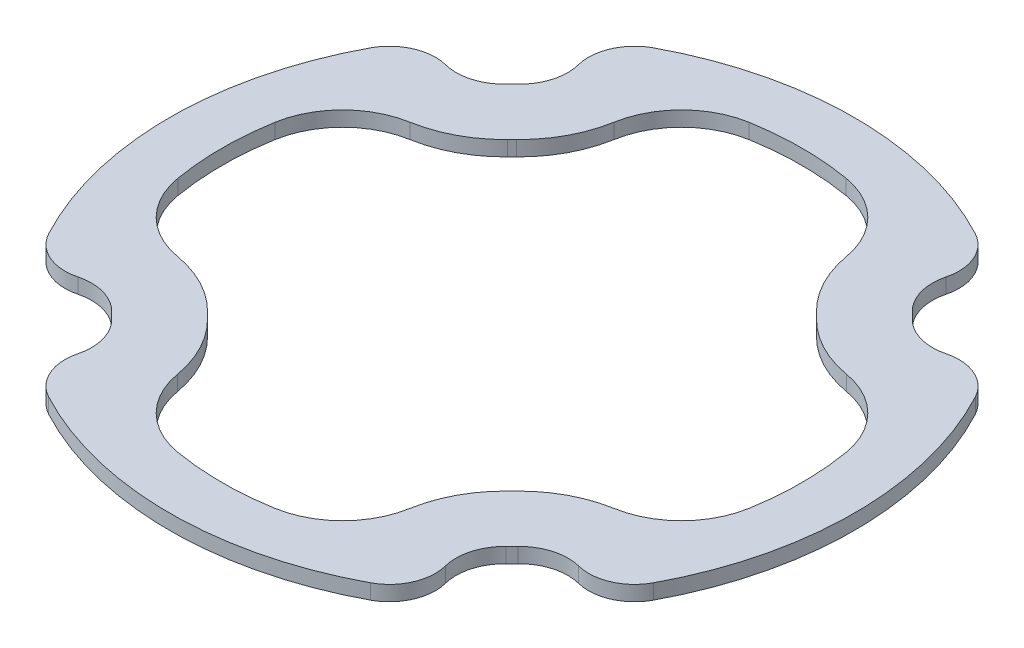
from build123d import *

# Parameters (mm, degrees)
PCB_OUTLINE_OUTER_DEPTH = 1
CUT_EXTRUDE2_DEPTH      = 1
CUT_EXTRUDE2_DEPTH_BACK = 2


with BuildPart() as part:
    # Internal Slab → PCB Outline Outer (new body)
    with BuildSketch(Plane(origin=(0, 0, 0), x_dir=(1, 0, 0), z_dir=(0, 1, 0))):
        with BuildLine():
            ThreePointArc((20.085113617, 10.68413361), (18.622288868, 12.043250737), (16.632261242, 12.207097181))
            ThreePointArc((16.632261242, 12.207097181), (14.943199752, 12.226998501), (13.492265758, 13.091935102))
            ThreePointArc((13.492265758, 13.091935102), (13.293607486, 13.293607486), (13.091935102, 13.492265758))
            ThreePointArc((13.091935102, 13.492265758), (12.226998501, 14.943199752), (12.207097181, 16.632261242))
            ThreePointArc((12.207097181, 16.632261242), (12.278791735, 17.008431368), (12.302815994, 17.390618375))
            ThreePointArc((12.302815994, 17.390618375), (11.867033623, 18.962276517), (10.68413361, 20.085113617))
            ThreePointArc((10.68413361, 20.085113617), (0, 22.75), (-10.68413361, 20.085113617))
            ThreePointArc((-10.68413361, 20.085113617), (-12.043250737, 18.622288868), (-12.207097181, 16.632261242))
            ThreePointArc((-12.207097181, 16.632261242), (-12.226998501, 14.943199752), (-13.091935102, 13.492265758))
            ThreePointArc((-13.091935102, 13.492265758), (-13.293607486, 13.293607486), (-13.492265758, 13.091935102))
            ThreePointArc((-13.492265758, 13.091935102), (-14.943199752, 12.226998501), (-16.632261242, 12.207097181))
            ThreePointArc((-16.632261242, 12.207097181), (-17.008431368, 12.278791735), (-17.390618375, 12.302815994))
            ThreePointArc((-17.390618375, 12.302815994), (-18.962276517, 11.867033623), (-20.085113617, 10.68413361))
            ThreePointArc((-20.085113617, 10.68413361), (-22.75, 0), (-20.085113617, -10.68413361))
            ThreePointArc((-20.085113617, -10.68413361), (-18.622288868, -12.043250737), (-16.632261242, -12.207097181))
            ThreePointArc((-16.632261242, -12.207097181), (-14.943199752, -12.226998501), (-13.492265758, -13.091935102))
            ThreePointArc((-13.492265758, -13.091935102), (-13.293607486, -13.293607486), (-13.091935102, -13.492265758))
            ThreePointArc((-13.091935102, -13.492265758), (-12.226998501, -14.943199752), (-12.207097181, -16.632261242))
            ThreePointArc((-12.207097181, -16.632261242), (-12.278791735, -17.008431368), (-12.302815994, -17.390618375))
            ThreePointArc((-12.302815994, -17.390618375), (-11.867033623, -18.962276517), (-10.68413361, -20.085113617))
            ThreePointArc((-10.68413361, -20.085113617), (0, -22.75), (10.68413361, -20.085113617))
            ThreePointArc((10.68413361, -20.085113617), (12.043250737, -18.622288868), (12.207097181, -16.632261242))
            ThreePointArc((12.207097181, -16.632261242), (12.226998501, -14.943199752), (13.091935102, -13.492265758))
            ThreePointArc((13.091935102, -13.492265758), (13.293607486, -13.293607486), (13.492265758, -13.091935102))
            ThreePointArc((13.492265758, -13.091935102), (14.943199752, -12.226998501), (16.632261242, -12.207097181))
            ThreePointArc((16.632261242, -12.207097181), (17.008431368, -12.278791735), (17.390618375, -12.302815994))
            ThreePointArc((17.390618375, -12.302815994), (18.962276517, -11.867033623), (20.085113617, -10.68413361))
            ThreePointArc((20.085113617, -10.68413361), (22.75, 0), (20.085113617, 10.68413361))
        make_face()
    extrude(amount=PCB_OUTLINE_OUTER_DEPTH)

    # Sketch7 → Cut-Extrude2 (cut, two sides)
    with BuildSketch(Plane(origin=(0, 1, 0), x_dir=(1, 0, 0), z_dir=(0, 1, 0))) as cut_extrude2_sk:
        with BuildLine():
            ThreePointArc((0, 19.25), (-1.616279551, 19.182026494), (-3.221144642, 18.978586017))
            ThreePointArc((-3.221144642, 18.978586017), (-6.18224043, 17.452869559), (-7.719604793, 14.497804451))
            ThreePointArc((-7.719604793, 14.497804451), (-8.503489746, 12.202965765), (-9.958227232, 10.262734061))
            ThreePointArc((-9.958227232, 10.262734061), (-10.111626971, 10.111626971), (-10.262734061, 9.958227232))
            ThreePointArc((-10.262734061, 9.958227232), (-12.202965765, 8.503489746), (-14.497804451, 7.719604793))
            ThreePointArc((-14.497804451, 7.719604793), (-17.452869559, 6.18224043), (-18.978586017, 3.221144642))
            ThreePointArc((-18.978586017, 3.221144642), (-19.182026494, 1.616279551), (-19.25, 0))
            ThreePointArc((-19.25, 0), (-19.182026494, -1.616279551), (-18.978586017, -3.221144642))
            ThreePointArc((-18.978586017, -3.221144642), (-17.452869559, -6.18224043), (-14.497804451, -7.719604793))
            ThreePointArc((-14.497804451, -7.719604793), (-12.202965765, -8.503489746), (-10.262734061, -9.958227232))
            ThreePointArc((-10.262734061, -9.958227232), (-10.111626971, -10.111626971), (-9.958227232, -10.262734061))
            ThreePointArc((-9.958227232, -10.262734061), (-8.503489746, -12.202965765), (-7.719604793, -14.497804451))
            ThreePointArc((-7.719604793, -14.497804451), (-6.18224043, -17.452869559), (-3.221144642, -18.978586017))
            ThreePointArc((-3.221144642, -18.978586017), (-1.616279551, -19.182026494), (0, -19.25))
            ThreePointArc((0, -19.25), (1.616279551, -19.182026494), (3.221144642, -18.978586017))
            ThreePointArc((3.221144642, -18.978586017), (6.18224043, -17.452869559), (7.719604793, -14.497804451))
            ThreePointArc((7.719604793, -14.497804451), (8.503489746, -12.202965765), (9.958227232, -10.262734061))
            ThreePointArc((9.958227232, -10.262734061), (10.111626971, -10.111626971), (10.262734061, -9.958227232))
            ThreePointArc((10.262734061, -9.958227232), (12.202965765, -8.503489746), (14.497804451, -7.719604793))
            ThreePointArc((14.497804451, -7.719604793), (17.452869559, -6.18224043), (18.978586017, -3.221144642))
            ThreePointArc((18.978586017, -3.221144642), (19.182026494, -1.616279551), (19.25, 0))
            ThreePointArc((19.25, 0), (19.182026494, 1.616279551), (18.978586017, 3.221144642))
            ThreePointArc((18.978586017, 3.221144642), (17.452869559, 6.18224043), (14.497804451, 7.719604793))
            ThreePointArc((14.497804451, 7.719604793), (12.202965765, 8.503489746), (10.262734061, 9.958227232))
            ThreePointArc((10.262734061, 9.958227232), (10.111626971, 10.111626971), (9.958227232, 10.262734061))
            ThreePointArc((9.958227232, 10.262734061), (8.503489746, 12.202965765), (7.719604793, 14.497804451))
            ThreePointArc((7.719604793, 14.497804451), (6.18224043, 17.452869559), (3.221144642, 18.978586017))
            ThreePointArc((3.221144642, 18.978586017), (1.616279551, 19.182026494), (0, 19.25))
        make_face()
    extrude(amount=CUT_EXTRUDE2_DEPTH, mode=Mode.SUBTRACT)
    extrude(cut_extrude2_sk.sketch, amount=-CUT_EXTRUDE2_DEPTH_BACK, mode=Mode.SUBTRACT)


solid = part.part
